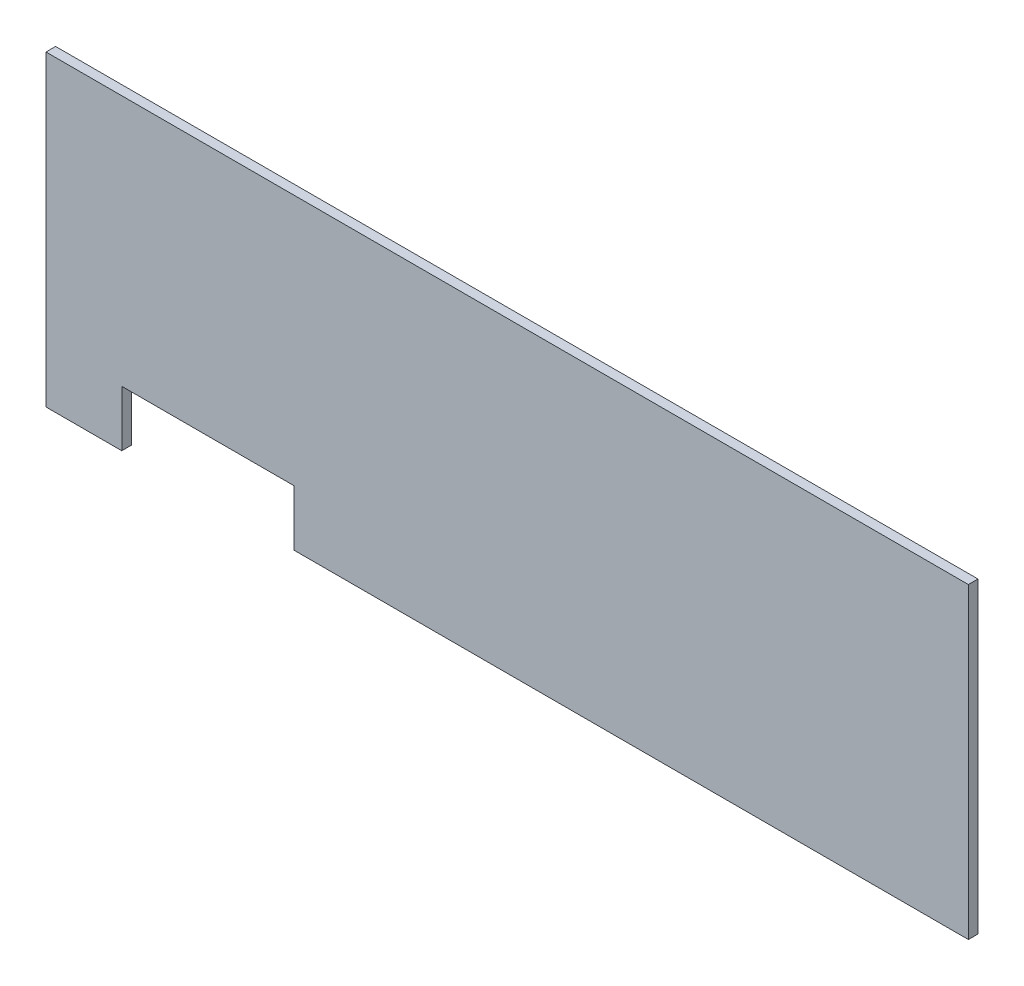
from build123d import *

# Parameters (mm, degrees)
BOSS_EXTRUDE1_DEPTH = 3.175


with BuildPart() as part:
    # Sketch1 → Boss-Extrude1 (new body)
    with BuildSketch(Plane.XY):
        Polygon((-70.490497222, -50.8), (152.4, -50.8), (152.4, 50.8), (-152.4, 50.8), (-152.4, -50.8), (-127.362849329, -50.8), (-127.362849329, -32.34860766), (-70.490497222, -32.34860766), align=None)
    extrude(amount=BOSS_EXTRUDE1_DEPTH)


solid = part.part
